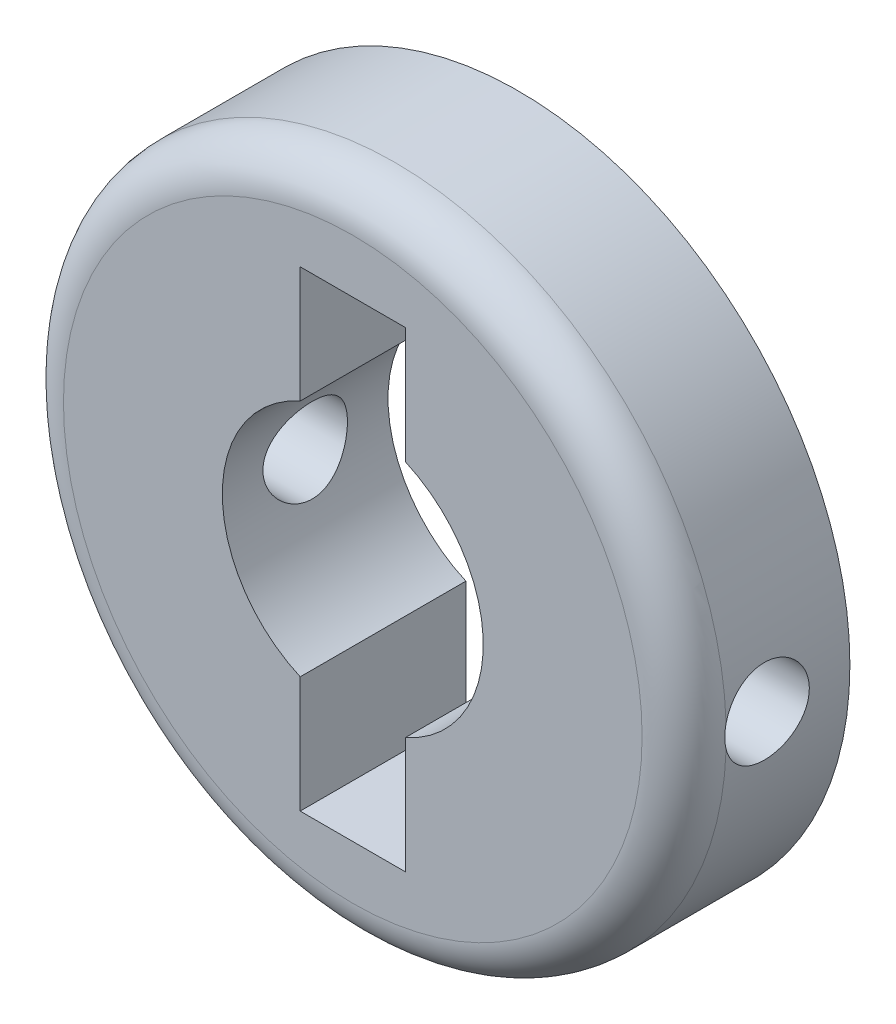
from build123d import *

# Parameters (mm, degrees)
SKETCH1_R               = 10
BOSS_EXTRUDE1_DEPTH     = 2.5
SKETCH4_R               = 1.275
CUT_EXTRUDE1_DEPTH      = 11
CUT_EXTRUDE1_DEPTH_BACK = 11
FILLET1_R               = 1.27


with BuildPart() as part:
    # Sketch1 → Boss-Extrude1 (new body, symmetric)
    with BuildSketch(Plane.XY):
        Circle(SKETCH1_R)
        with BuildLine():
            Line((1.5875, 3.60275072), (1.5875, 7.112))
            Line((1.5875, 7.112), (-1.5875, 7.112))
            Line((-1.5875, 7.112), (-1.5875, 3.60275072))
            ThreePointArc((-1.5875, 3.60275072), (-3.937, 0), (-1.5875, -3.60275072))
            Line((-1.5875, -3.60275072), (-1.5875, -7.112))
            Line((-1.5875, -7.112), (1.5875, -7.112))
            Line((1.5875, -7.112), (1.5875, -3.60275072))
            ThreePointArc((1.5875, -3.60275072), (3.937, 0), (1.5875, 3.60275072))
        make_face(mode=Mode.SUBTRACT)
    extrude(amount=BOSS_EXTRUDE1_DEPTH, both=True)

    # Sketch4 → Cut-Extrude1 (cut, two sides)
    with BuildSketch(Plane(origin=(0, 0, 0), x_dir=(0, 0, -1), z_dir=(1, 0, 0))) as cut_extrude1_sk:
        Circle(SKETCH4_R)
    extrude(amount=CUT_EXTRUDE1_DEPTH, mode=Mode.SUBTRACT)
    extrude(cut_extrude1_sk.sketch, amount=-CUT_EXTRUDE1_DEPTH_BACK, mode=Mode.SUBTRACT)

    # Fillet1
    fillet1_edges = [part.edges().sort_by_distance(p)[0] for p in [
        (-10, 0, 2.5),
    ]]
    fillet(fillet1_edges, radius=FILLET1_R)


solid = part.part
